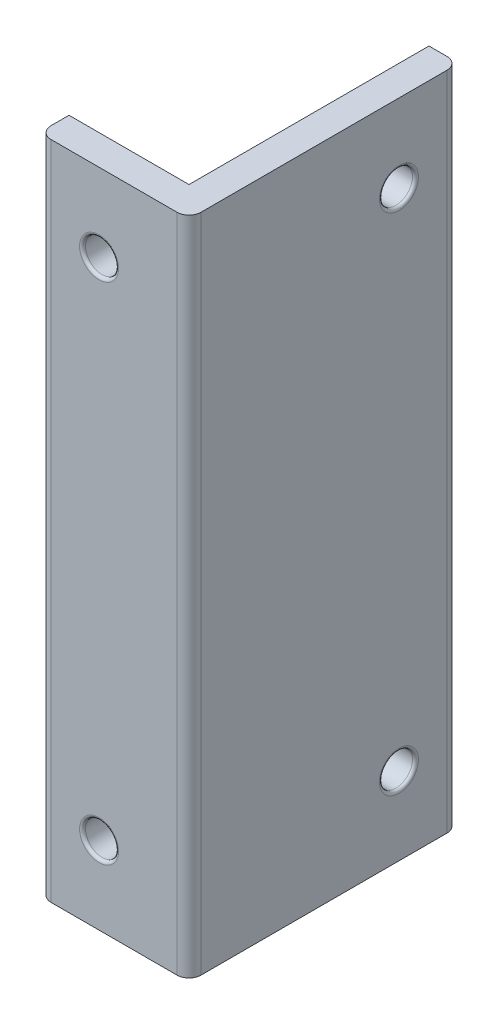
from build123d import *

# Parameters (mm, degrees)
BOSS_EXTRUDE1_DEPTH = 110.14
SKETCH2_R           = 2.75
CUT_EXTRUDE1_DEPTH  = 46
SKETCH3_R           = 2.75
CUT_EXTRUDE2_DEPTH  = 26
FILLET1_R           = 0.5
FILLET2_R           = 2


with BuildPart() as part:
    # Sketch1 → Boss-Extrude1 (new body)
    with BuildSketch(Plane(origin=(0, 0, 0), x_dir=(1, 0, 0), z_dir=(0, 1, 0))):
        Polygon((-12.5, -2.5), (12.5, -2.5), (12.5, 2.5), (12.5, 42.5), (7.5, 42.5), (7.5, 2.5), (-12.5, 2.5), align=None)
    extrude(amount=BOSS_EXTRUDE1_DEPTH)

    # Sketch2 → Cut-Extrude1 (cut, through all)
    with BuildSketch(Plane.XY.offset(2.5)):
        with Locations((-2.5, 97.14)):
            Circle(SKETCH2_R)
        with Locations((-2.5, 13)):
            Circle(SKETCH2_R)
    extrude(amount=-CUT_EXTRUDE1_DEPTH, mode=Mode.SUBTRACT)

    # Sketch3 → Cut-Extrude2 (cut, through all)
    with BuildSketch(Plane(origin=(12.5, 0, 0), x_dir=(0, 0, -1), z_dir=(1, 0, 0))):
        with Locations((32.5, 97.14)):
            Circle(SKETCH3_R)
        with Locations((32.5, 13)):
            Circle(SKETCH3_R)
    extrude(amount=-CUT_EXTRUDE2_DEPTH, mode=Mode.SUBTRACT)

    # Fillet1
    fillet1_edges = [part.edges().sort_by_distance(p)[0] for p in [
        (-5.25, 13, -2.5),
        (-5.25, 13, 2.5),
        (-5.25, 97.14, -2.5),
        (-5.25, 97.14, 2.5),
        (7.5, 97.14, -29.75),
        (12.5, 97.14, -29.75),
        (7.5, 13, -29.75),
        (12.5, 13, -29.75),
    ]]
    fillet(fillet1_edges, radius=FILLET1_R)

    # Fillet2
    fillet2_edges = [part.edges().sort_by_distance(p)[0] for p in [
        (12.5, 55.07, 2.5),
        (-12.5, 55.07, 2.5),
        (12.5, 55.07, -42.5),
    ]]
    fillet(fillet2_edges, radius=FILLET2_R)


solid = part.part
